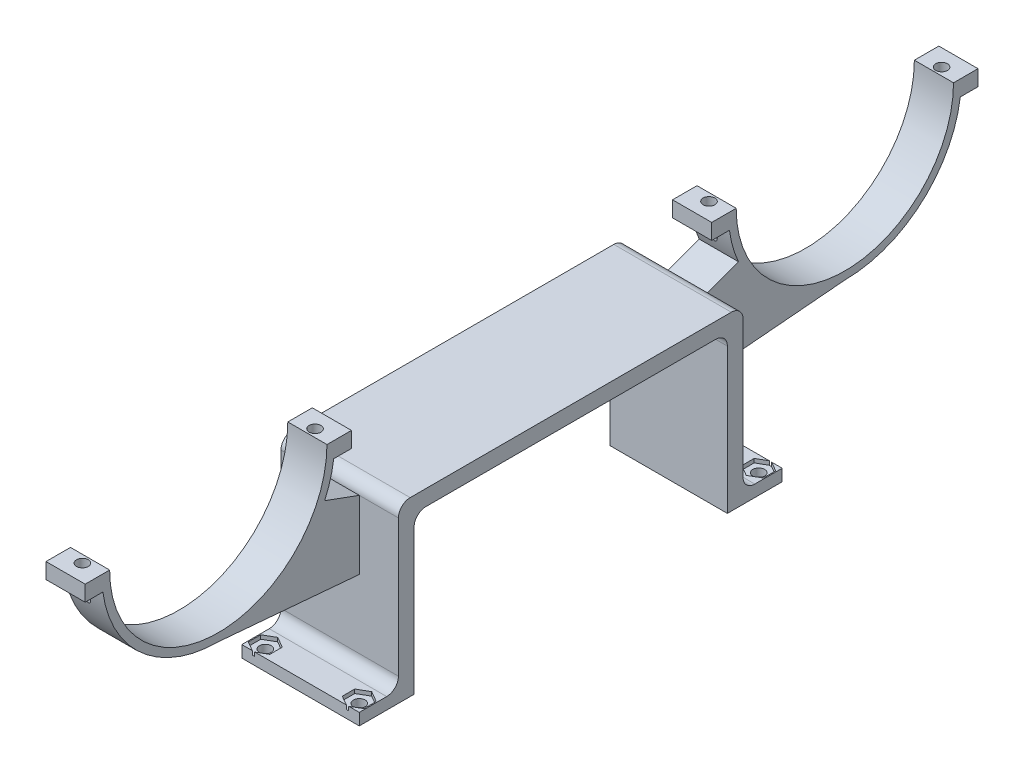
from build123d import *

# Parameters (mm, degrees)
EXTRUDE_1_DEPTH      = 15
EXTRUDE_1_DEPTH_BACK = 15
EXTRUDE_2_DEPTH      = 5
EXTRUDE_2_DEPTH_BACK = 5
EXTRUDE_2_START      = -15
SKETCH_3_R           = 1.5
CUT_EXTRUDE_1_DEPTH  = 11
SKETCH_4_R           = 1.5
CUT_EXTRUDE_2_DEPTH  = 11
CUT_EXTRUDE_3_DEPTH  = 1


with BuildPart() as part:
    # 草图1 → 凸台-拉伸1 (new, two sides: drawn at the far end of the back side and taken through both)
    with BuildSketch(Plane(origin=(0, 0, 0), x_dir=(0, 0, -1), z_dir=(1, 0, 0)).offset(-EXTRUDE_1_DEPTH_BACK)):
        with BuildLine():
            Line((-40, -0.344795888), (-40, 36.655204112))
            ThreePointArc((-40, 36.655204112), (-39.121320344, 38.776524455), (-37, 39.655204112))
            Line((-37, 39.655204112), (37, 39.655204112))
            ThreePointArc((37, 39.655204112), (39.121320344, 38.776524455), (40, 36.655204112))
            Line((40, 36.655204112), (40, -0.344795888))
            Line((40, -0.344795888), (54, -0.344795888))
            Line((54, -0.344795888), (54, 2.655204112))
            Line((54, 2.655204112), (47, 2.655204112))
            ThreePointArc((47, 2.655204112), (44.878679656, 3.533883768), (44, 5.655204112))
            Line((44, 5.655204112), (44, 40.655204112))
            ThreePointArc((44, 40.655204112), (43.121320344, 42.776524455), (41, 43.655204112))
            Line((41, 43.655204112), (-41, 43.655204112))
            ThreePointArc((-41, 43.655204112), (-43.121320344, 42.776524455), (-44, 40.655204112))
            Line((-44, 40.655204112), (-44, 5.655204112))
            ThreePointArc((-44, 5.655204112), (-44.878679656, 3.533883768), (-47, 2.655204112))
            Line((-47, 2.655204112), (-54, 2.655204112))
            Line((-54, 2.655204112), (-54, -0.344795888))
            Line((-54, -0.344795888), (-40, -0.344795888))
        make_face()
    extrude(amount=EXTRUDE_1_DEPTH + EXTRUDE_1_DEPTH_BACK)

    # 草图2 → 凸台-拉伸2 (add, two sides: drawn at the far end of the back side and taken through both)
    with BuildSketch(Plane(origin=(15, 0, 0), x_dir=(0, 0, -1), z_dir=(1, 0, 0)).offset(EXTRUDE_2_START - EXTRUDE_2_DEPTH_BACK)):
        with BuildLine():
            Line((-52.25, 56.016603057), (-46, 56.016603057))
            Line((-46, 56.016603057), (-46, 52.016603057))
            Line((-46, 52.016603057), (-50.520133989, 52.016603057))
            ThreePointArc((-50.520133989, 52.016603057), (-51.385897915, 47.874388257), (-52.830611648, 43.896915082))
            Line((-52.830611648, 43.896915082), (-44, 40.655204112))
            Line((-44, 40.655204112), (-44, 23.155204112))
            Line((-44, 23.155204112), (-80, 26.266603057))
            ThreePointArc((-80, 26.266603057), (-99.571184175, 33.610549187), (-109.479866011, 52.016603057))
            Line((-109.479866011, 52.016603057), (-114, 52.016603057))
            Line((-114, 52.016603057), (-114, 56.016603057))
            Line((-114, 56.016603057), (-107.75, 56.016603057))
            ThreePointArc((-107.75, 56.016603057), (-80, 28.266603057), (-52.25, 56.016603057))
        make_face()
        with BuildLine():
            Line((52.830611648, 43.896915082), (44, 40.655204112))
            Line((44, 40.655204112), (44, 23.155204112))
            Line((44, 23.155204112), (80, 26.266603057))
            ThreePointArc((80, 26.266603057), (99.571184175, 33.610549187), (109.479866011, 52.016603057))
            Line((109.479866011, 52.016603057), (114, 52.016603057))
            Line((114, 52.016603057), (114, 56.016603057))
            Line((114, 56.016603057), (107.75, 56.016603057))
            ThreePointArc((107.75, 56.016603057), (80, 28.266603057), (52.25, 56.016603057))
            Line((52.25, 56.016603057), (46, 56.016603057))
            Line((46, 56.016603057), (46, 52.016603057))
            Line((46, 52.016603057), (50.520133989, 52.016603057))
            ThreePointArc((50.520133989, 52.016603057), (51.385897915, 47.874388257), (52.830611648, 43.896915082))
        make_face()
    extrude(amount=EXTRUDE_2_DEPTH + EXTRUDE_2_DEPTH_BACK)

    # 草图3 → 切除-拉伸1 (cut)
    with BuildSketch(Plane(origin=(0, 56.016603057, 0), x_dir=(1, 0, 0), z_dir=(0, 1, 0))):
        with Locations((0, 109.7)):
            Circle(SKETCH_3_R)
        with Locations((0, 50.3)):
            Circle(SKETCH_3_R)
        with Locations((0, -50.3)):
            Circle(SKETCH_3_R)
        with Locations((0, -109.7)):
            Circle(SKETCH_3_R)
    extrude(amount=-CUT_EXTRUDE_1_DEPTH, mode=Mode.SUBTRACT)

    # 草图4 → 切除-拉伸2 (cut)
    with BuildSketch(Plane(origin=(0, 2.655204112, 0), x_dir=(1, 0, 0), z_dir=(0, 1, 0))):
        with Locations((-12, -51)):
            Circle(SKETCH_4_R)
        with Locations((12, -51)):
            Circle(SKETCH_4_R)
        with Locations((12, 51)):
            Circle(SKETCH_4_R)
        with Locations((-12, 51)):
            Circle(SKETCH_4_R)
    extrude(amount=-CUT_EXTRUDE_2_DEPTH, mode=Mode.SUBTRACT)

    # 草图5 → 切除-拉伸3 (cut)
    with BuildSketch(Plane(origin=(0, 2.655204112, 0), x_dir=(1, 0, 0), z_dir=(0, 1, 0))):
        Polygon((-12, 54.175426481), (-14.75, 52.58771324), (-14.75, 49.41228676), (-12, 47.824573519), (-9.25, 49.41228676), (-9.25, 52.58771324), align=None)
        Polygon((12, 54.175426481), (9.25, 52.58771324), (9.25, 49.41228676), (12, 47.824573519), (14.75, 49.41228676), (14.75, 52.58771324), align=None)
        Polygon((14.75, -52.58771324), (12, -54.175426481), (9.25, -52.58771324), (9.25, -49.41228676), (12, -47.824573519), (14.75, -49.41228676), align=None)
        Polygon((-9.25, -52.58771324), (-12, -54.175426481), (-14.75, -52.58771324), (-14.75, -49.41228676), (-12, -47.824573519), (-9.25, -49.41228676), align=None)
    extrude(amount=-CUT_EXTRUDE_3_DEPTH, mode=Mode.SUBTRACT)


solid = part.part
